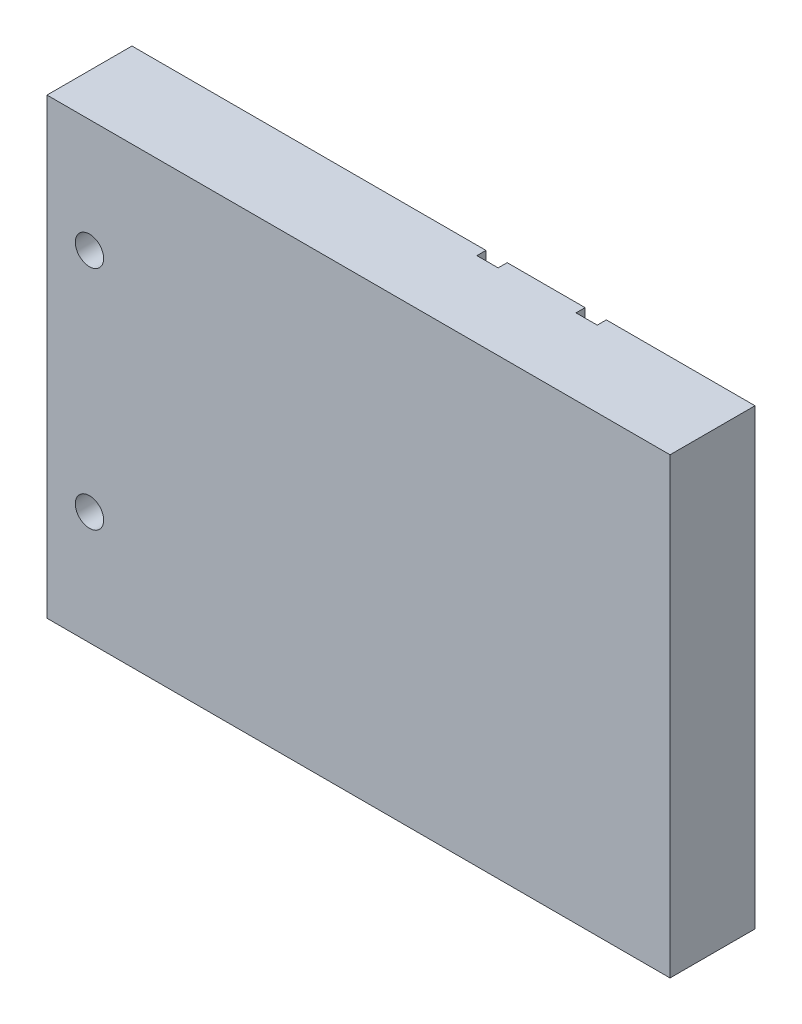
from build123d import *

# Parameters (mm, degrees)
BOSS_EXTRUDE3_DEPTH         = 50.8
F_1_4_0_25_DIAMETER_HOLE1_D = 6.35


with BuildPart() as part:
    # 3DSketch2 → Boss-Extrude3 (new, symmetric)
    with BuildSketch(Plane(origin=(69.85, 0, -9.525), x_dir=(-0.990830168044299, 0, 0.1351132047333135), z_dir=(0, -1, 0))):
        Polygon((0, 0), (33.031800727, 4.504336463), (33.306350759, 2.490969561), (38.025179435, 3.134446199), (37.750629402, 5.1478131), (55.053001212, 7.507227438), (55.327551244, 5.493860537), (60.046379919, 6.137337174), (59.771829887, 8.150704076), (138.418974476, 18.875314701), (140.992881026, 0), (2.57390655, -18.875314701), align=None)
    extrude(amount=BOSS_EXTRUDE3_DEPTH, both=True)

    # 1/4 (0.25) Diameter Hole1 (through all)
    with Locations(Plane(origin=(0, 0, -9.525), x_dir=(-1, 0, 0), z_dir=(0, 0, -1))):
        with Locations((60.325, -25.4), (60.325, 25.4)):
            Hole(F_1_4_0_25_DIAMETER_HOLE1_D / 2)


solid = part.part
